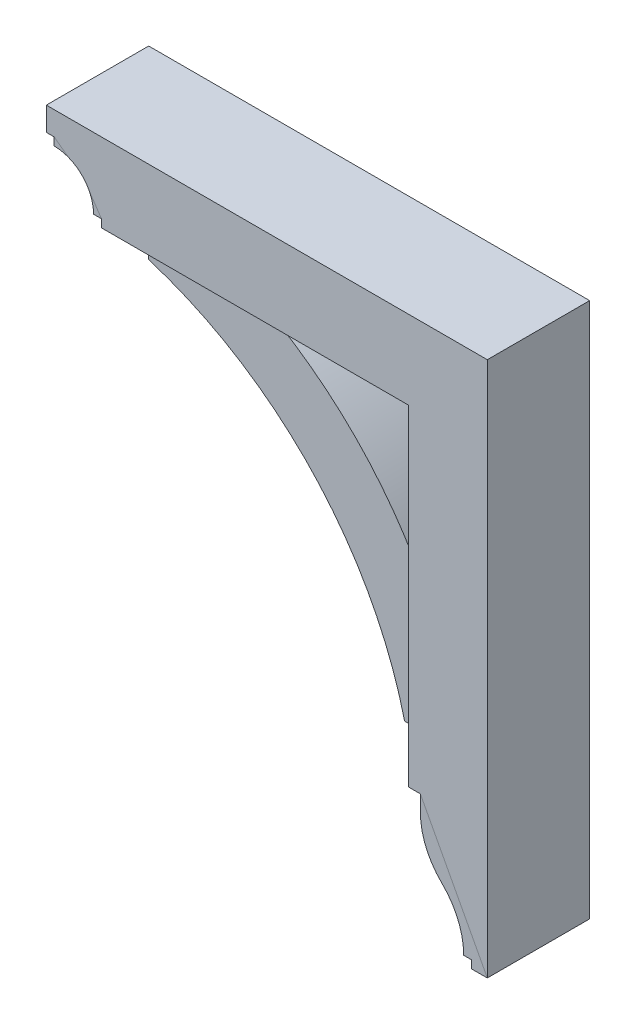
from build123d import *

# Parameters (mm, degrees)
BOSS_EXTRUDE1_DEPTH = 41.275
BOSS_EXTRUDE2_DEPTH = 28.575
BOSS_EXTRUDE3_DEPTH = 41.275


with BuildPart() as part:
    # Sketch1 → Boss-Extrude1 (new body, symmetric)
    with BuildSketch(Plane.XY):
        with BuildLine():
            Line((297.681223016, -285.115), (297.681223016, 146.685))
            Line((297.681223016, 146.685), (-57.918776984, 146.685))
            Line((-57.918776984, 146.685), (-57.918776984, 127.635))
            Line((-57.918776984, 127.635), (-51.568776984, 127.635))
            Line((-51.568776984, 127.635), (-51.568776984, 121.285))
            ThreePointArc((-51.568776984, 121.285), (-29.118136682, 111.985640303), (-19.818776984, 89.535))
            Line((-19.818776984, 89.535), (-13.468776984, 89.535))
            Line((-13.468776984, 89.535), (-13.468776984, 83.185))
            Line((-13.468776984, 83.185), (234.181223016, 83.185))
            Line((234.181223016, 83.185), (234.181223016, -183.515))
            Line((234.181223016, -183.515), (243.706223016, -183.515))
            Line((243.706223016, -183.515), (243.706223016, -196.215))
            ThreePointArc((243.706223016, -196.215), (248.222944617, -218.482925476), (261.059171573, -237.231060226))
            ThreePointArc((261.059171573, -237.231060226), (274.057472101, -256.215913848), (278.631223016, -278.765))
            Line((278.631223016, -278.765), (284.981223016, -278.765))
            Line((284.981223016, -278.765), (284.981223016, -285.115))
            Line((284.981223016, -285.115), (297.681223016, -285.115))
        make_face()
    extrude(amount=BOSS_EXTRUDE1_DEPTH, both=True)


with BuildPart() as body_2:
    # Sketch1_3 → Boss-Extrude2 (new body, symmetric)
    with BuildSketch(Plane.XY):
        with BuildLine():
            Line((218.306223016, -151.765), (234.181223016, -151.765))
            Line((234.181223016, -151.765), (234.181223016, -50.165))
            ThreePointArc((234.181223016, -50.165), (178.618723016, 26.705907738), (102.418723016, 83.185))
            Line((102.418723016, 83.185), (11.931223016, 83.185))
            Line((11.931223016, 83.185), (11.931223016, 67.31))
            ThreePointArc((11.931223016, 67.31), (144.044926072, -14.97817828), (218.306223016, -151.765))
        make_face()
    extrude(amount=BOSS_EXTRUDE2_DEPTH, both=True)


with BuildPart() as body_3:
    # Sketch1_4 → Boss-Extrude3 (new body, symmetric)
    with BuildSketch(Plane.XY):
        with BuildLine():
            Line((297.681223016, -285.115), (297.681223016, 146.685))
            Line((297.681223016, 146.685), (-57.918776984, 146.685))
            Line((-57.918776984, 146.685), (-57.918776984, 127.635))
            Line((-57.918776984, 127.635), (-51.568776984, 127.635))
            Line((-51.568776984, 127.635), (-51.568776984, 121.285))
            ThreePointArc((-51.568776984, 121.285), (-29.118136682, 111.985640303), (-19.818776984, 89.535))
            Line((-19.818776984, 89.535), (-13.468776984, 89.535))
            Line((-13.468776984, 89.535), (-13.468776984, 83.185))
            Line((-13.468776984, 83.185), (234.181223016, 83.185))
            Line((234.181223016, 83.185), (234.181223016, -183.515))
            Line((234.181223016, -183.515), (243.706223016, -183.515))
            Line((243.706223016, -183.515), (243.706223016, -196.215))
            ThreePointArc((243.706223016, -196.215), (248.222944617, -218.482925476), (261.059171573, -237.231060226))
            ThreePointArc((261.059171573, -237.231060226), (274.057472101, -256.215913848), (278.631223016, -278.765))
            Line((278.631223016, -278.765), (284.981223016, -278.765))
            Line((284.981223016, -278.765), (284.981223016, -285.115))
            Line((284.981223016, -285.115), (297.681223016, -285.115))
        make_face()
    extrude(amount=BOSS_EXTRUDE3_DEPTH, both=True)


solid = Compound([part.part, body_2.part, body_3.part])
